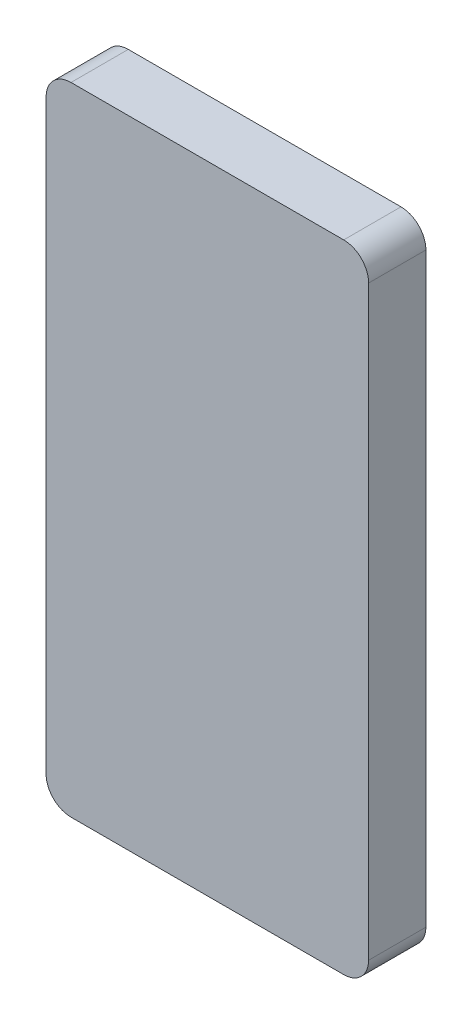
from build123d import *

# Parameters (mm, degrees)
SKETCH1_W           = 65.786
SKETCH1_H           = 129.794
BOSS_EXTRUDE1_DEPTH = 11.684
FILLET1_R           = 5.08


with BuildPart() as part:
    # Sketch1 → Boss-Extrude1 (new body)
    with BuildSketch(Plane.XY):
        Rectangle(SKETCH1_W, SKETCH1_H)
    extrude(amount=BOSS_EXTRUDE1_DEPTH)

    # Fillet1
    fillet1_edges = [part.edges().sort_by_distance(p)[0] for p in [
        (32.893, -64.897, 5.842),
        (-32.893, -64.897, 5.842),
        (-32.893, 64.897, 5.842),
        (32.893, 64.897, 5.842),
    ]]
    fillet(fillet1_edges, radius=FILLET1_R)


solid = part.part
